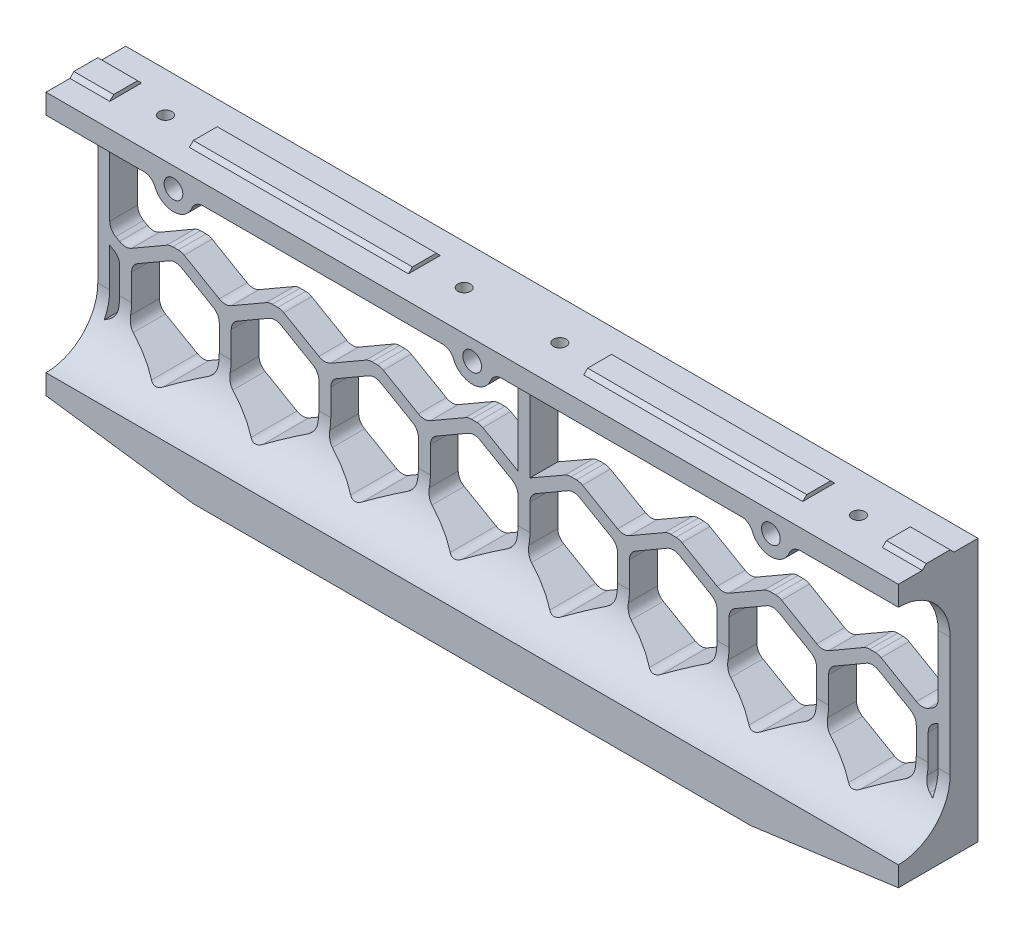
from build123d import *

# Parameters (mm, degrees)
BOSS_EXTRUDE1_DEPTH           = 107
SKETCH8_W                     = 70
SKETCH8_H                     = 20
BOSS_EXTRUDE2_DEPTH           = 9
SKETCH2_W                     = 20
SKETCH2_H                     = 8
SKETCH2_W_2                   = 22
RAILBUMP_DEPTH                = 1
SKETCH3_R                     = 1.6
RAILMOUNTHOLE_DEPTH           = 5
MOUNTING_START                = -4
SKETCH6_R                     = 3
MOUNTING_HOLE_CLEARANCE_DEPTH = 10
HONEYPATTERNCUTOUTS_DEPTH     = 21
FRONT_CARVEOUT_DEPTH          = 108
FILLET3_R                     = 3
FILLET3_OF_MIRROR1_R          = 3
BOSS_EXTRUDE14_DEPTH          = 20
SKETCH23_R                    = 2.35
CUT_EXTRUDE6_DEPTH            = 7
FILLET4_R                     = 3
BASEPIECE_DEPTH               = 20


with BuildPart() as part:
    # Sketch1 → Boss-Extrude1 (new body)
    with BuildSketch(Plane(origin=(0, 0, 0), x_dir=(0, 0, -1), z_dir=(1, 0, 0))):
        Polygon((20, 0), (14, 0), (13, 1), (7, 1), (6, 0), (0, 0), (0, -66), (5, -66), (11, -62), (20, -62), align=None)
    boss_extrude1 = extrude(amount=BOSS_EXTRUDE1_DEPTH)

    # Sketch8 → Boss-Extrude2 (add)
    with BuildSketch(Plane.XZ.offset(62)):
        with Locations((35, -10)):
            Rectangle(SKETCH8_W, SKETCH8_H)
    boss_extrude2 = extrude(amount=BOSS_EXTRUDE2_DEPTH)

    # Sketch2 → RailBump (cut)
    with BuildSketch(Plane(origin=(0, 1, 0), x_dir=(1, 0, 0), z_dir=(0, 1, 0))):
        with Locations((87, 10)):
            Rectangle(SKETCH2_W, SKETCH2_H)
        with Locations((11, 10)):
            Rectangle(SKETCH2_W_2, SKETCH2_H)
    railbump = extrude(amount=-RAILBUMP_DEPTH, mode=Mode.SUBTRACT)

    # Sketch3 → RailMountHole (cut)
    with BuildSketch(Plane(origin=(0, 0, 0), x_dir=(1, 0, 0), z_dir=(0, 1, 0))):
        with Locations((87, 10)):
            Circle(SKETCH3_R)
        with Locations((12, 10)):
            Circle(SKETCH3_R)
    railmounthole = extrude(amount=-RAILMOUNTHOLE_DEPTH, mode=Mode.SUBTRACT)

    # Sketch6 → Mounting hole clearance (cut)
    with BuildSketch(Plane(origin=(0, 0, 0), x_dir=(1, 0, 0), z_dir=(0, 1, 0)).offset(MOUNTING_START)):
        with Locations((87, 10)):
            Circle(SKETCH6_R)
        with Locations((12, 10)):
            Circle(SKETCH6_R)
    mounting_hole_clearance = extrude(amount=-MOUNTING_HOLE_CLEARANCE_DEPTH, mode=Mode.SUBTRACT)

    # Sketch4 → HoneyPatternCutouts (cut, through all)
    with BuildSketch(Plane(origin=(0, 0, -20), x_dir=(-1, 0, 0), z_dir=(0, 0, -1))):
        Polygon((-61, -30.699782134), (-50, -37.050635095), (-39, -30.699782134), (-36, -30.699782134), (-25, -37.050635095), (-14, -30.699782134), (-11, -30.699782134), (-1.5, -36.127105407), (-1.5, -5), (-104, -5), (-104, -34.790381057), (-100.028375056, -37.083399787), (-89, -30.71616448), (-86, -30.699782134), (-75, -37.050635095), (-64, -30.699782134), align=None)
        Polygon((-37.5, -58.701270189), (-26.5, -52.350417228), (-26.5, -39.648711306), (-37.5, -33.297858345), (-48.5, -39.648711306), (-48.5, -52.350417228), align=None)
        Polygon((-12.5, -58.701270189), (-1.5, -52.350417228), (-1.5, -39.648711306), (-12.5, -33.297858345), (-23.5, -39.648711306), (-23.5, -52.350417228), align=None)
        Polygon((-76.5, -52.350417228), (-76.5, -39.648711306), (-87.5, -33.297858345), (-98.5, -39.648711306), (-98.5, -52.350417228), (-87.5, -58.701270189), align=None)
        Polygon((-51.5, -52.350417228), (-51.5, -39.648711306), (-62.5, -33.297858345), (-73.5, -39.648711306), (-73.5, -52.350417228), (-62.5, -58.701270189), align=None)
        Polygon((-101.5, -39.697858345), (-104, -38.254482672), (-104, -53.818366421), (-101.5, -52.374990748), align=None)
    honeypatterncutouts = extrude(amount=-HONEYPATTERNCUTOUTS_DEPTH, mode=Mode.SUBTRACT)

    # Sketch5 → Front CarveOut (cut, through all)
    with BuildSketch(Plane(origin=(107, 0, 0), x_dir=(0, 0, -1), z_dir=(1, 0, 0))):
        with BuildLine():
            Line((13, -18), (13, -48))
            ThreePointArc((13, -48), (9.192388155, -57.192388155), (0, -61))
            Line((0, -61), (0, -5))
            ThreePointArc((0, -5), (9.192388155, -8.807611845), (13, -18))
        make_face()
    front_carveout = extrude(amount=-FRONT_CARVEOUT_DEPTH, mode=Mode.SUBTRACT)

    # Fillet3
    fillet3_edges = [part.edges().sort_by_distance(p)[0] for p in [
        (104, -5, -10),
        (104, -34.790381057, -16.5),
        (101.5, -52.374990748, -16.120854841),
        (101.5, -39.697858345, -16.5),
        (98.5, -39.648711306, -16.5),
        (98.5, -52.350417228, -16.125232035),
        (100.028375056, -37.083399787, -16.5),
        (89, -30.71616448, -16.5),
        (86, -30.699782134, -16.5),
        (87.5, -33.297858345, -16.5),
        (76.5, -39.648711306, -16.5),
        (87.5, -58.701270189, -13.690623807),
        (76.5, -52.350417228, -16.125232035),
        (62.5, -58.701270189, -13.690623807),
        (73.5, -52.350417228, -16.125232035),
        (73.5, -39.648711306, -16.5),
        (62.5, -33.297858345, -16.5),
        (75, -37.050635095, -16.5),
        (61, -30.699782134, -16.5),
        (64, -30.699782134, -16.5),
        (51.5, -39.648711306, -16.5),
        (51.5, -52.350417228, -16.125232035),
        (48.5, -39.648711306, -16.5),
        (37.5, -33.297858345, -16.5),
        (26.5, -39.648711306, -16.5),
        (26.5, -52.350417228, -16.125232035),
        (37.5, -58.701270189, -13.690623807),
        (48.5, -52.350417228, -16.125232035),
        (50, -37.050635095, -16.5),
        (39, -30.699782134, -16.5),
        (36, -30.699782134, -16.5),
        (25, -37.050635095, -16.5),
        (14, -30.699782134, -16.5),
        (11, -30.699782134, -16.5),
        (1.5, -52.350417228, -16.125232035),
        (12.5, -58.701270189, -13.690623807),
        (23.5, -52.350417228, -16.125232035),
        (23.5, -39.648711306, -16.5),
        (12.5, -33.297858345, -16.5),
        (1.5, -39.648711306, -16.5),
    ]]
    fillet(fillet3_edges, radius=FILLET3_R)

    # Mirror1: Boss-Extrude1, Boss-Extrude2, RailBump, RailMountHole, Mounting hole clearance, HoneyPatternCutouts, Front CarveOut across plane
    add(boss_extrude1.mirror(Plane(origin=(0, 0, 0), x_dir=(0, 0, 1), z_dir=(1, 0, 0))))
    add(boss_extrude2.mirror(Plane(origin=(0, 0, 0), x_dir=(0, 0, 1), z_dir=(1, 0, 0))))
    add(railbump.mirror(Plane(origin=(0, 0, 0), x_dir=(0, 0, 1), z_dir=(1, 0, 0))), mode=Mode.SUBTRACT)
    add(railmounthole.mirror(Plane(origin=(0, 0, 0), x_dir=(0, 0, 1), z_dir=(1, 0, 0))), mode=Mode.SUBTRACT)
    add(mounting_hole_clearance.mirror(Plane(origin=(0, 0, 0), x_dir=(0, 0, 1), z_dir=(1, 0, 0))), mode=Mode.SUBTRACT)
    add(honeypatterncutouts.mirror(Plane(origin=(0, 0, 0), x_dir=(0, 0, 1), z_dir=(1, 0, 0))), mode=Mode.SUBTRACT)
    add(front_carveout.mirror(Plane(origin=(0, 0, 0), x_dir=(0, 0, 1), z_dir=(1, 0, 0))), mode=Mode.SUBTRACT)

    # Fillet3 of Mirror1
    fillet3_of_mirror1_edges = [part.edges().sort_by_distance(p)[0] for p in [
        (-104, -5, -10),
        (-104, -34.790381057, -16.5),
        (-101.5, -52.374990748, -16.120854841),
        (-101.5, -39.697858345, -16.5),
        (-98.5, -39.648711306, -16.5),
        (-98.5, -52.350417228, -16.125232035),
        (-100.028375056, -37.083399787, -16.5),
        (-89, -30.71616448, -16.5),
        (-86, -30.699782134, -16.5),
        (-87.5, -33.297858345, -16.5),
        (-76.5, -39.648711306, -16.5),
        (-87.5, -58.701270189, -13.690623807),
        (-76.5, -52.350417228, -16.125232035),
        (-62.5, -58.701270189, -13.690623807),
        (-73.5, -52.350417228, -16.125232035),
        (-73.5, -39.648711306, -16.5),
        (-62.5, -33.297858345, -16.5),
        (-75, -37.050635095, -16.5),
        (-61, -30.699782134, -16.5),
        (-64, -30.699782134, -16.5),
        (-51.5, -39.648711306, -16.5),
        (-51.5, -52.350417228, -16.125232035),
        (-48.5, -39.648711306, -16.5),
        (-37.5, -33.297858345, -16.5),
        (-26.5, -39.648711306, -16.5),
        (-26.5, -52.350417228, -16.125232035),
        (-37.5, -58.701270189, -13.690623807),
        (-48.5, -52.350417228, -16.125232035),
        (-50, -37.050635095, -16.5),
        (-39, -30.699782134, -16.5),
        (-36, -30.699782134, -16.5),
        (-25, -37.050635095, -16.5),
        (-14, -30.699782134, -16.5),
        (-11, -30.699782134, -16.5),
        (-1.5, -52.350417228, -16.125232035),
        (-12.5, -58.701270189, -13.690623807),
        (-23.5, -52.350417228, -16.125232035),
        (-23.5, -39.648711306, -16.5),
        (-12.5, -33.297858345, -16.5),
        (-1.5, -39.648711306, -16.5),
    ]]
    fillet(fillet3_of_mirror1_edges, radius=FILLET3_OF_MIRROR1_R)

    # Sketch22 → Boss-Extrude14 (add)
    with BuildSketch(Plane(origin=(0, 0, 0), x_dir=(-1, 0, 0), z_dir=(0, 0, -1))):
        with BuildLine():
            Line((80, -5), (70, -5))
            ThreePointArc((70, -5), (75, -10), (80, -5))
        make_face()
        with BuildLine():
            Line((5, -5), (-5, -5))
            ThreePointArc((-5, -5), (0, -10), (5, -5))
        make_face()
        with BuildLine():
            Line((-80, -5), (-70, -5))
            ThreePointArc((-70, -5), (-75, -10), (-80, -5))
        make_face()
    extrude(amount=BOSS_EXTRUDE14_DEPTH)

    # Sketch23 → Cut-Extrude6 (cut)
    with BuildSketch(Plane(origin=(0, 0, 0), x_dir=(-1, 0, 0), z_dir=(0, 0, -1))):
        with Locations((-75, -5)):
            Circle(SKETCH23_R)
        with Locations((0, -5)):
            Circle(SKETCH23_R)
        with Locations((75, -5)):
            Circle(SKETCH23_R)
    extrude(amount=CUT_EXTRUDE6_DEPTH, mode=Mode.SUBTRACT)

    # Fillet4
    fillet4_edges = [part.edges().sort_by_distance(p)[0] for p in [
        (-5, -5, -10),
        (5, -5, -10),
        (-80, -5, -10),
        (-70, -5, -10),
        (70, -5, -10),
        (80, -5, -10),
    ]]
    fillet(fillet4_edges, radius=FILLET4_R)

    # Sketch10 → BasePiece (add)
    with BuildSketch(Plane(origin=(0, 0, -20), x_dir=(-1, 0, 0), z_dir=(0, 0, -1))):
        Polygon((70, -71), (70, -62), (107, -62), (107, -66), align=None)
        Polygon((-70, -71), (-107, -66), (-107, -62), (-70, -62), align=None)
    extrude(amount=-BASEPIECE_DEPTH)


solid = part.part
